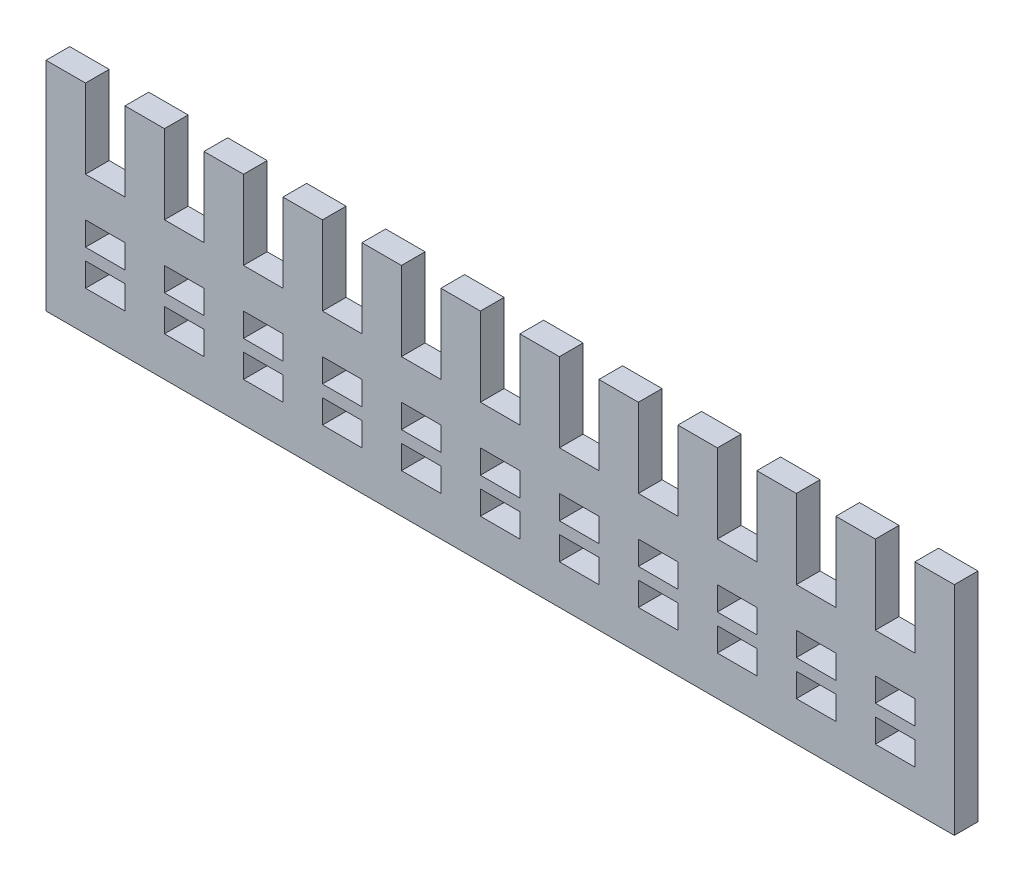
from build123d import *

# Parameters (mm, degrees)
ESQUISSE1_W        = 5
ESQUISSE1_H        = 3
BOSS_EXTRU_1_DEPTH = 3


with BuildPart() as part:
    # Esquisse1 → Boss.-Extru.1 (new body)
    with BuildSketch(Plane.XY):
        Polygon((-127.914818772, 46.520106884), (-127.914818772, 36.520106884), (-132.914818772, 36.520106884), (-132.914818772, 46.520106884), (-137.914818772, 46.520106884), (-137.914818772, 19.020106884), (-22.914818772, 19.020106884), (-22.914818772, 46.520106884), (-27.914818772, 46.520106884), (-27.914818772, 36.520106884), (-32.914818772, 36.520106884), (-32.914818772, 46.520106884), (-37.914818772, 46.520106884), (-37.914818772, 36.520106884), (-42.914818772, 36.520106884), (-42.914818772, 46.520106884), (-47.914818772, 46.520106884), (-47.914818772, 36.520106884), (-52.914818772, 36.520106884), (-52.914818772, 46.520106884), (-57.914818772, 46.520106884), (-57.914818772, 36.520106884), (-62.914818772, 36.520106884), (-62.914818772, 46.520106884), (-67.914818772, 46.520106884), (-67.914818772, 36.520106884), (-72.914818772, 36.520106884), (-72.914818772, 46.520106884), (-77.914818772, 46.520106884), (-77.914818772, 36.520106884), (-82.914818772, 36.520106884), (-82.914818772, 46.520106884), (-87.914818772, 46.520106884), (-87.914818772, 36.520106884), (-92.914818772, 36.520106884), (-92.914818772, 46.520106884), (-97.914818772, 46.520106884), (-97.914818772, 36.520106884), (-102.914818772, 36.520106884), (-102.914818772, 46.520106884), (-107.914818772, 46.520106884), (-107.914818772, 36.520106884), (-112.914818772, 36.520106884), (-112.914818772, 46.520106884), (-117.914818772, 46.520106884), (-117.914818772, 36.520106884), (-122.914818772, 36.520106884), (-122.914818772, 46.520106884), align=None)
        with Locations((-30.414818772, 30.020106884)):
            Rectangle(ESQUISSE1_W, ESQUISSE1_H, mode=Mode.SUBTRACT)
        with Locations((-40.414818772, 30.020106884)):
            Rectangle(ESQUISSE1_W, ESQUISSE1_H, mode=Mode.SUBTRACT)
        with Locations((-50.414818772, 30.020106884)):
            Rectangle(ESQUISSE1_W, ESQUISSE1_H, mode=Mode.SUBTRACT)
        with Locations((-60.414818772, 30.020106884)):
            Rectangle(ESQUISSE1_W, ESQUISSE1_H, mode=Mode.SUBTRACT)
        with Locations((-70.414818772, 30.020106884)):
            Rectangle(ESQUISSE1_W, ESQUISSE1_H, mode=Mode.SUBTRACT)
        with Locations((-80.414818772, 30.020106884)):
            Rectangle(ESQUISSE1_W, ESQUISSE1_H, mode=Mode.SUBTRACT)
        with Locations((-90.414818772, 30.020106884)):
            Rectangle(ESQUISSE1_W, ESQUISSE1_H, mode=Mode.SUBTRACT)
        with Locations((-100.414818772, 30.020106884)):
            Rectangle(ESQUISSE1_W, ESQUISSE1_H, mode=Mode.SUBTRACT)
        with Locations((-30.414818772, 25.520106884)):
            Rectangle(ESQUISSE1_W, ESQUISSE1_H, mode=Mode.SUBTRACT)
        with Locations((-40.414818772, 25.520106884)):
            Rectangle(ESQUISSE1_W, ESQUISSE1_H, mode=Mode.SUBTRACT)
        with Locations((-50.414818772, 25.520106884)):
            Rectangle(ESQUISSE1_W, ESQUISSE1_H, mode=Mode.SUBTRACT)
        with Locations((-60.414818772, 25.520106884)):
            Rectangle(ESQUISSE1_W, ESQUISSE1_H, mode=Mode.SUBTRACT)
        with Locations((-70.414818772, 25.520106884)):
            Rectangle(ESQUISSE1_W, ESQUISSE1_H, mode=Mode.SUBTRACT)
        with Locations((-80.414818772, 25.520106884)):
            Rectangle(ESQUISSE1_W, ESQUISSE1_H, mode=Mode.SUBTRACT)
        with Locations((-90.414818772, 25.520106884)):
            Rectangle(ESQUISSE1_W, ESQUISSE1_H, mode=Mode.SUBTRACT)
        with Locations((-100.414818772, 25.520106884)):
            Rectangle(ESQUISSE1_W, ESQUISSE1_H, mode=Mode.SUBTRACT)
        with Locations((-110.414818772, 25.520106884)):
            Rectangle(ESQUISSE1_W, ESQUISSE1_H, mode=Mode.SUBTRACT)
        with Locations((-120.414818772, 25.520106884)):
            Rectangle(ESQUISSE1_W, ESQUISSE1_H, mode=Mode.SUBTRACT)
        with Locations((-110.414818772, 30.020106884)):
            Rectangle(ESQUISSE1_W, ESQUISSE1_H, mode=Mode.SUBTRACT)
        with Locations((-130.414818772, 25.520106884)):
            Rectangle(ESQUISSE1_W, ESQUISSE1_H, mode=Mode.SUBTRACT)
        with Locations((-120.414818772, 30.020106884)):
            Rectangle(ESQUISSE1_W, ESQUISSE1_H, mode=Mode.SUBTRACT)
        with Locations((-130.414818772, 30.020106884)):
            Rectangle(ESQUISSE1_W, ESQUISSE1_H, mode=Mode.SUBTRACT)
    extrude(amount=BOSS_EXTRU_1_DEPTH)


solid = part.part
